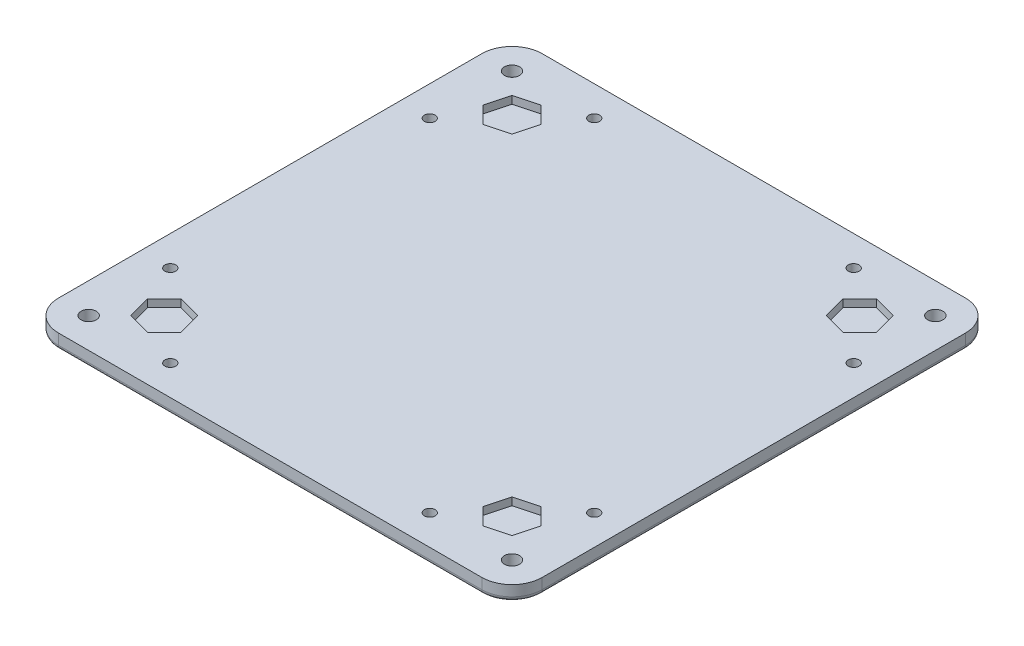
from build123d import *

# Parameters (mm, degrees)
SKETCH1_W           = 203.2
SKETCH1_H           = 203.2
BOSS_EXTRUDE1_DEPTH = 6.35
FILLET1_R           = 12.7
SKETCH2_R           = 3.175
CUT_EXTRUDE1_DEPTH  = 7.35
CUT_EXTRUDE2_DEPTH  = 3.175
FILLET2_R           = 1.905
SKETCH28_R          = 2.286
CUT_EXTRUDE3_DEPTH  = 7.35


with BuildPart() as part:
    # Sketch1 → Boss-Extrude1 (new body)
    with BuildSketch(Plane(origin=(0, 0, 0), x_dir=(1, 0, 0), z_dir=(0, 1, 0))):
        with Locations((101.6, 101.6)):
            Rectangle(SKETCH1_W, SKETCH1_H)
    extrude(amount=BOSS_EXTRUDE1_DEPTH)

    # Fillet1
    fillet1_edges = [part.edges().sort_by_distance(p)[0] for p in [
        (0, 3.175, -203.2),
        (203.2, 3.175, -203.2),
        (203.2, 3.175, 0),
        (0, 3.175, 0),
    ]]
    fillet(fillet1_edges, radius=FILLET1_R)

    # Sketch2 → Cut-Extrude1 (cut, through all)
    with BuildSketch(Plane.XZ):
        with Locations((12.7, -12.7)):
            Circle(SKETCH2_R)
        with Locations((190.5, -12.7)):
            Circle(SKETCH2_R)
        with Locations((190.5, -190.5)):
            Circle(SKETCH2_R)
        with Locations((12.7, -190.5)):
            Circle(SKETCH2_R)
    extrude(amount=-CUT_EXTRUDE1_DEPTH, mode=Mode.SUBTRACT)

    # Sketch22 → Cut-Extrude2 (cut)
    with BuildSketch(Plane(origin=(0, 6.35, 0), x_dir=(1, 0, 0), z_dir=(0, 1, 0))):
        Polygon((181.654219065, 181.654219065), (172.052127253, 184.227091812), (165.022908188, 177.197872747), (167.595780935, 167.595780935), (177.197872747, 165.022908188), (184.227091812, 172.052127253), align=None)
        Polygon((18.972908188, 172.052127253), (21.545780935, 181.654219065), (31.147872747, 184.227091812), (38.177091812, 177.197872747), (35.604219065, 167.595780935), (26.002127253, 165.022908188), align=None)
        Polygon((184.227091812, 31.147872747), (181.654219065, 21.545780935), (172.052127253, 18.972908188), (165.022908188, 26.002127253), (167.595780935, 35.604219065), (177.197872747, 38.177091812), align=None)
        Polygon((21.545780935, 21.545780935), (31.147872747, 18.972908188), (38.177091812, 26.002127253), (35.604219065, 35.604219065), (26.002127253, 38.177091812), (18.972908188, 31.147872747), align=None)
    extrude(amount=-CUT_EXTRUDE2_DEPTH, mode=Mode.SUBTRACT)

    # Fillet2
    fillet2_edges = [part.edges().sort_by_distance(p)[0] for p in [
        (0, 0, -101.6),
        (101.6, 0, -203.2),
        (203.2, 0, -101.6),
        (101.6, 0, 0),
        (199.480256121, 0, -199.480256121),
        (199.480256121, 0, -3.719743879),
        (3.719743879, 0, -3.719743879),
        (3.719743879, 0, -199.480256121),
        (9.525, 0, -190.5),
        (187.325, 0, -190.5),
        (187.325, 0, -12.7),
        (9.525, 0, -12.7),
    ]]
    fillet(fillet2_edges, radius=FILLET2_R)

    # Sketch28 → Cut-Extrude3 (cut, through all)
    with BuildSketch(Plane(origin=(0, 6.35, 0), x_dir=(1, 0, 0), z_dir=(0, 1, 0))):
        with Locations((47.117, 190.627)):
            Circle(SKETCH28_R)
        with Locations((156.083, 190.627)):
            Circle(SKETCH28_R)
        with Locations((190.627, 156.083)):
            Circle(SKETCH28_R)
        with Locations((190.627, 47.117)):
            Circle(SKETCH28_R)
        with Locations((156.083, 12.573)):
            Circle(SKETCH28_R)
        with Locations((47.117, 12.573)):
            Circle(SKETCH28_R)
        with Locations((12.573, 156.083)):
            Circle(SKETCH28_R)
        with Locations((12.573, 47.117)):
            Circle(SKETCH28_R)
    extrude(amount=-CUT_EXTRUDE3_DEPTH, mode=Mode.SUBTRACT)


solid = part.part
